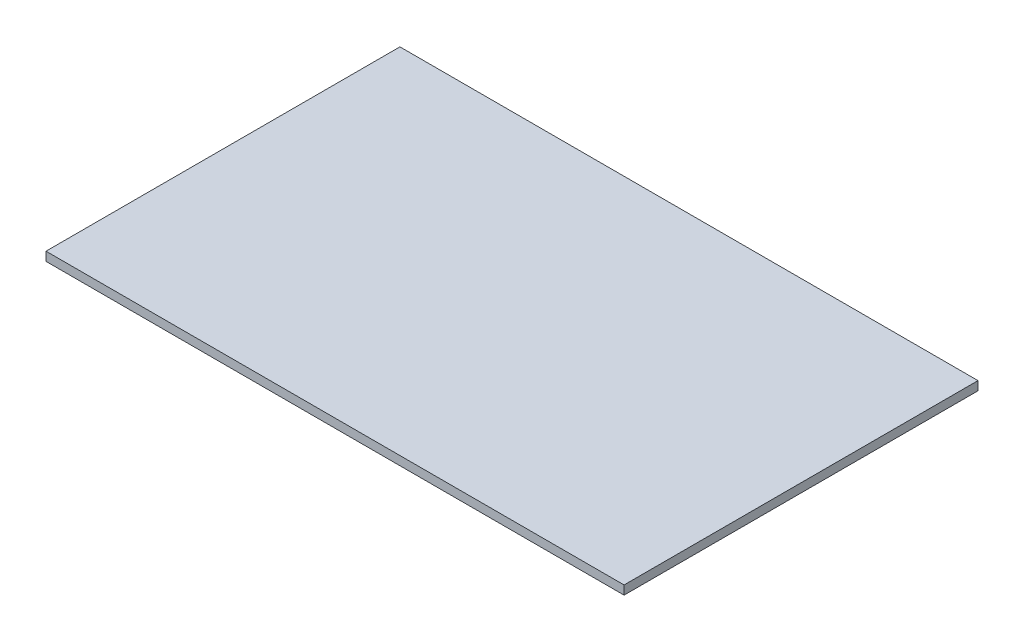
from build123d import *

# Parameters (mm, degrees)
SKETCH_1_W      = 98
SKETCH_1_H      = 60
EXTRUDE_1_DEPTH = 1.5


with BuildPart() as part:
    # Эскиз1 → Бобышка-Вытянуть1 (new body)
    with BuildSketch(Plane(origin=(0, 0, 0), x_dir=(1, 0, 0), z_dir=(0, 1, 0))):
        Rectangle(SKETCH_1_W, SKETCH_1_H)
    extrude(amount=EXTRUDE_1_DEPTH)


solid = part.part
